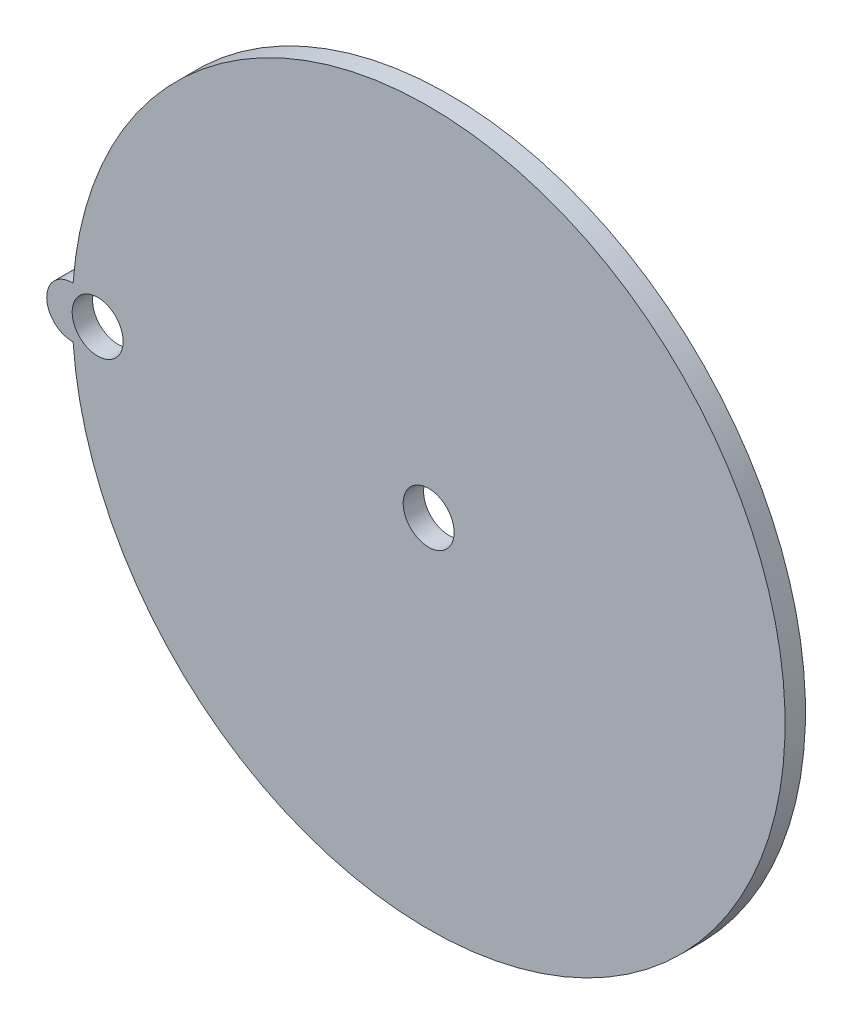
from build123d import *

# Parameters (mm, degrees)
SKETCH2_R           = 3.175
BOSS_EXTRUDE2_DEPTH = 2.54


with BuildPart() as part:
    # Sketch2 → Boss-Extrude2 (new body)
    with BuildSketch(Plane.XY):
        with BuildLine():
            ThreePointArc((-44.336607143, -3.172974481), (44.45, 0), (-44.336607143, 3.172974481))
            ThreePointArc((-44.336607143, 3.172974481), (-47.625, 0), (-44.336607143, -3.172974481))
        make_face()
        with Locations((-41.275, 0)):
            Circle(SKETCH2_R, mode=Mode.SUBTRACT)
        Circle(SKETCH2_R, mode=Mode.SUBTRACT)
    extrude(amount=BOSS_EXTRUDE2_DEPTH)


solid = part.part
